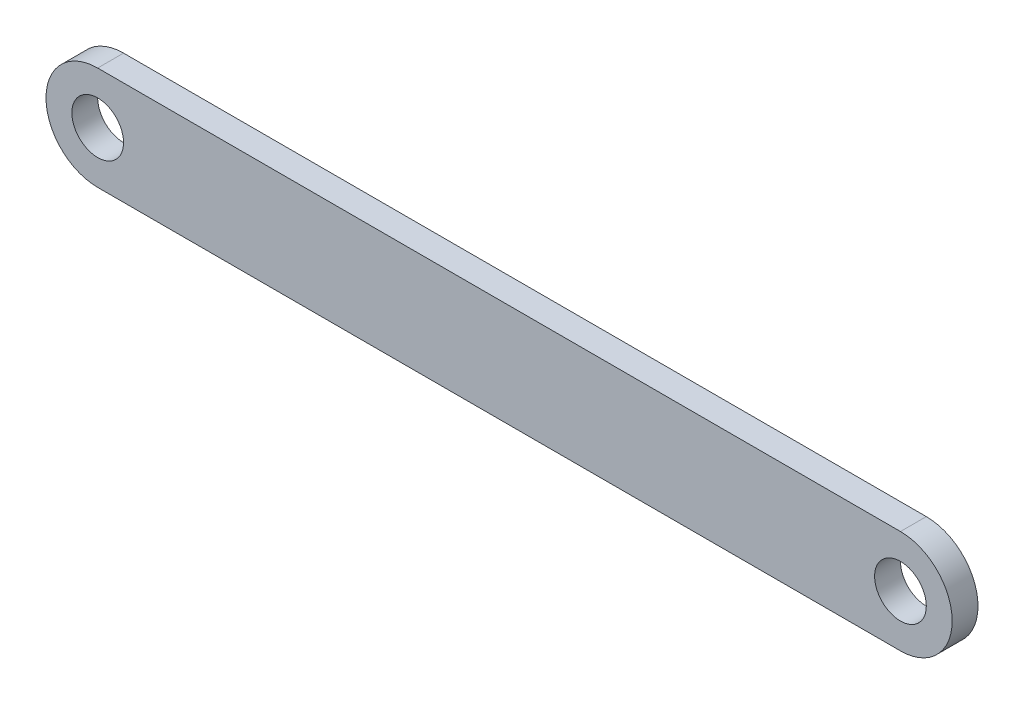
from build123d import *

# Parameters (mm, degrees)
SKETCH1_R           = 1
BOSS_EXTRUDE1_DEPTH = 1


with BuildPart() as part:
    # Sketch1 → Boss-Extrude1 (new body)
    with BuildSketch(Plane.XY):
        with BuildLine():
            Line((0, -2), (31.057177912, -2))
            ThreePointArc((31.057177912, -2), (33.057177912, 0), (31.057177912, 2))
            Line((31.057177912, 2), (0, 2))
            ThreePointArc((0, 2), (-2, 0), (0, -2))
        make_face()
        Circle(SKETCH1_R, mode=Mode.SUBTRACT)
        with Locations((31.057177912, 0)):
            Circle(SKETCH1_R, mode=Mode.SUBTRACT)
    extrude(amount=BOSS_EXTRUDE1_DEPTH)


solid = part.part
